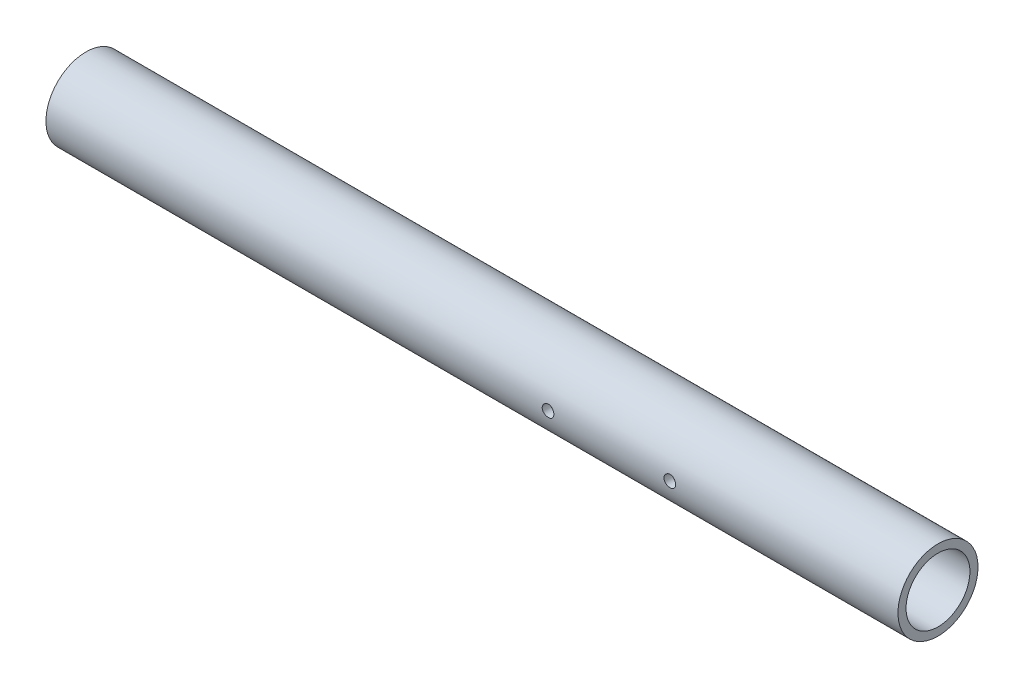
from build123d import *

# Parameters (mm, degrees)
SKETCH1_R               = 16.7005
SKETCH1_R_2             = 13.335
BOSS_EXTRUDE1_DEPTH     = 355.6
SKETCH2_R               = 2.4257
CUT_EXTRUDE1_DEPTH      = 17.7005
CUT_EXTRUDE1_DEPTH_BACK = 17.7005


with BuildPart() as part:
    # Sketch1 → Boss-Extrude1 (new body)
    with BuildSketch(Plane(origin=(0, 0, 0), x_dir=(0, 0, -1), z_dir=(1, 0, 0))):
        Circle(SKETCH1_R)
        Circle(SKETCH1_R_2, mode=Mode.SUBTRACT)
    extrude(amount=BOSS_EXTRUDE1_DEPTH)

    # Sketch2 → Cut-Extrude1 (cut, two sides)
    with BuildSketch(Plane.XY) as cut_extrude1_sk:
        with Locations((209.55, 0)):
            Circle(SKETCH2_R)
        with Locations((260.35, 0)):
            Circle(SKETCH2_R)
    extrude(amount=CUT_EXTRUDE1_DEPTH, mode=Mode.SUBTRACT)
    extrude(cut_extrude1_sk.sketch, amount=-CUT_EXTRUDE1_DEPTH_BACK, mode=Mode.SUBTRACT)


solid = part.part
